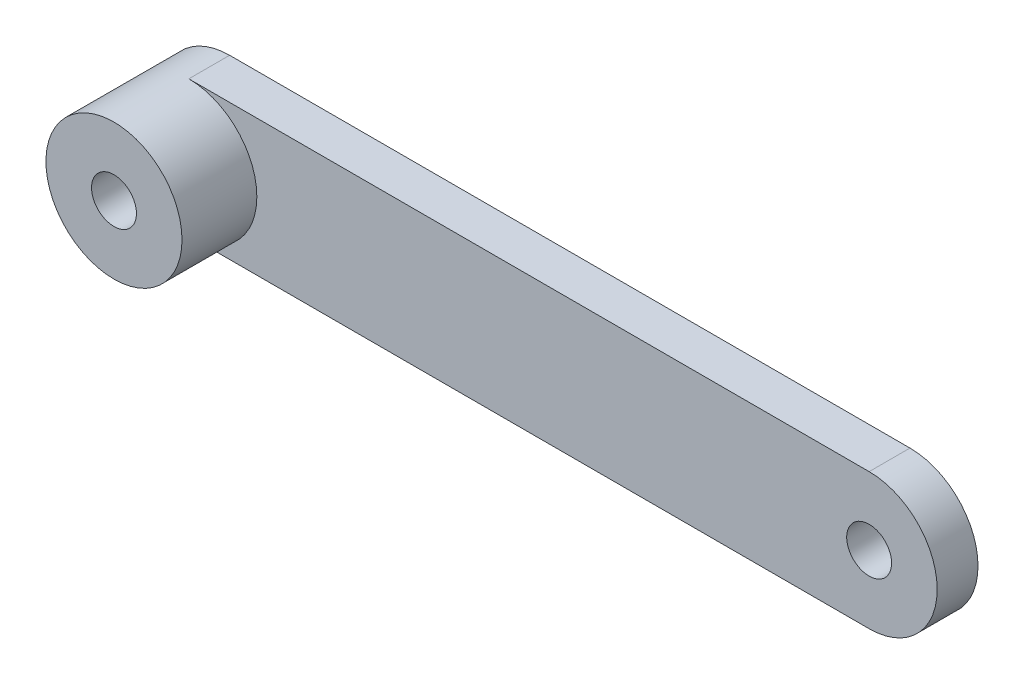
from build123d import *

# Parameters (mm, degrees)
SKETCH_1_R      = 1.65
EXTRUDE_1_DEPTH = 3
SKETCH_2_R      = 5
SKETCH_2_R_2    = 1.65
EXTRUDE_2_DEPTH = 5.5


with BuildPart() as part:
    # 草圖1 → 填料-伸長1 (new body)
    with BuildSketch(Plane.XY):
        with BuildLine():
            Line((0, 5), (50, 5))
            ThreePointArc((50, 5), (55, 0), (50, -5))
            Line((50, -5), (0, -5))
            ThreePointArc((0, -5), (-5, 0), (0, 5))
        make_face()
        Circle(SKETCH_1_R, mode=Mode.SUBTRACT)
        with Locations((50, 0)):
            Circle(SKETCH_1_R, mode=Mode.SUBTRACT)
    extrude(amount=EXTRUDE_1_DEPTH)

    # 草圖2 → 填料-伸長2 (add)
    with BuildSketch(Plane.XY.offset(3)):
        Circle(SKETCH_2_R)
        Circle(SKETCH_2_R_2, mode=Mode.SUBTRACT)
    extrude(amount=EXTRUDE_2_DEPTH)


solid = part.part
